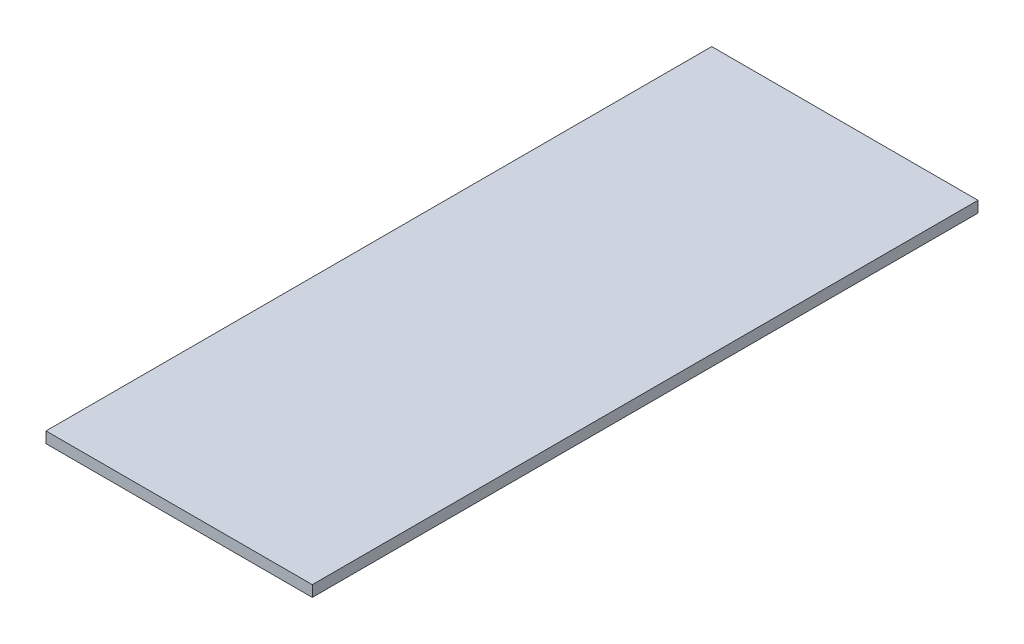
from build123d import *

# Parameters (mm, degrees)
SKETCH1_W           = 152.4
SKETCH1_H           = 381
BOSS_EXTRUDE1_DEPTH = 6.35


with BuildPart() as part:
    # Sketch1 → Boss-Extrude1 (new body)
    with BuildSketch(Plane(origin=(0, 0, 0), x_dir=(1, 0, 0), z_dir=(0, 1, 0))):
        with Locations((76.2, 190.5)):
            Rectangle(SKETCH1_W, SKETCH1_H)
    extrude(amount=BOSS_EXTRUDE1_DEPTH)


solid = part.part
